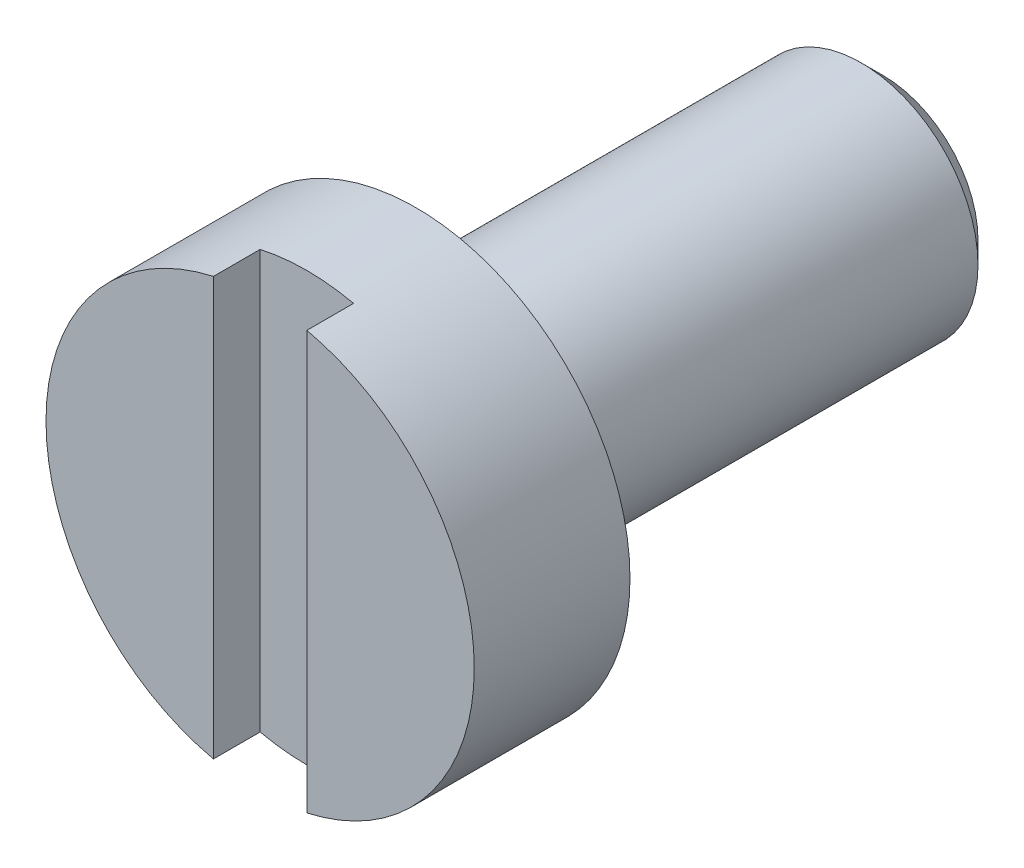
from build123d import *

# Parameters (mm, degrees)
SKETCH_1_R               = 2.75
EXTRUDE_1_DEPTH          = 2
SKETCH_2_R               = 1.5
EXTRUDE_2_DEPTH          = 6
CHAMFER_1_SIZE           = 0.2805
CUT_EXTRUDE_1_DEPTH      = 38
CUT_EXTRUDE_1_DEPTH_BACK = 38
SKETCH_3_W               = 1.2
SKETCH_3_H               = 1.2


with BuildPart() as part:
    # Эскиз1 → Бобышка-Вытянуть1 (new body)
    with BuildSketch(Plane.XY):
        Circle(SKETCH_1_R)
    extrude(amount=EXTRUDE_1_DEPTH)

    # Эскиз2 → Бобышка-Вытянуть2 (add)
    with BuildSketch(Plane(origin=(0, 0, 0), x_dir=(-1, 0, 0), z_dir=(0, 0, -1))):
        Circle(SKETCH_2_R)
    extrude(amount=EXTRUDE_2_DEPTH)

    # Фаска1
    chamfer_1_edges = [part.edges().sort_by_distance(p)[0] for p in [
        (1.5, 0, -6),
    ]]
    chamfer(chamfer_1_edges, length=CHAMFER_1_SIZE)

    # Эскиз3 → Вырез-Вытянуть1 (cut, two sides: drawn at the far end of the back side and taken through both)
    with BuildSketch(Plane(origin=(0, 0, 0), x_dir=(1, 0, 0), z_dir=(0, 1, 0)).offset(-CUT_EXTRUDE_1_DEPTH_BACK)):
        with Locations((0, -2)):
            Rectangle(SKETCH_3_W, SKETCH_3_H)
    extrude(amount=CUT_EXTRUDE_1_DEPTH + CUT_EXTRUDE_1_DEPTH_BACK, mode=Mode.SUBTRACT)


solid = part.part
